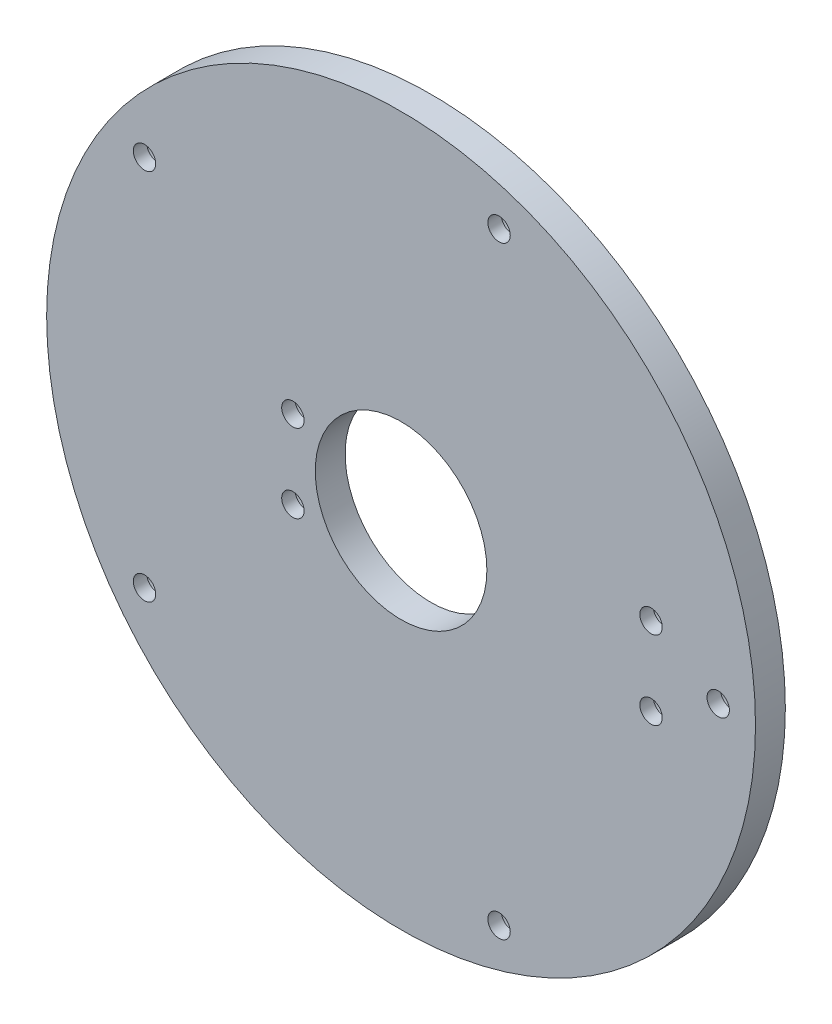
from build123d import *

# Parameters (mm, degrees)
SKETCH1_R           = 47.5
SKETCH1_R_2         = 2.75
SKETCH1_R_3         = 11.5
SKETCH1_R_4         = 1.5
BOSS_EXTRUDE2_DEPTH = 4
SKETCH1_5_R         = 2.75
SKETCH1_5_R_2       = 1.5
CUT_EXTRUDE1_DEPTH  = 2.2


with BuildPart() as part:
    # Sketch1 → Boss-Extrude2 (new body)
    with BuildSketch(Plane.XY):
        with Locations((47.5, 47.5)):
            Circle(SKETCH1_R)
        with Locations((81, 42.125)):
            Circle(SKETCH1_R_2, mode=Mode.SUBTRACT)
        with Locations((90, 47.5)):
            Circle(SKETCH1_R_2, mode=Mode.SUBTRACT)
        with Locations((81, 52.625)):
            Circle(SKETCH1_R_2, mode=Mode.SUBTRACT)
        with Locations((60.633222261, 87.919901943)):
            Circle(SKETCH1_R_2, mode=Mode.SUBTRACT)
        with Locations((13.116777739, 72.480873222)):
            Circle(SKETCH1_R_2, mode=Mode.SUBTRACT)
        with Locations((33, 52.625)):
            Circle(SKETCH1_R_2, mode=Mode.SUBTRACT)
        with Locations((33, 42.125)):
            Circle(SKETCH1_R_2, mode=Mode.SUBTRACT)
        with Locations((60.633222261, 7.080098057)):
            Circle(SKETCH1_R_2, mode=Mode.SUBTRACT)
        with Locations((13.116777739, 22.519126778)):
            Circle(SKETCH1_R_2, mode=Mode.SUBTRACT)
        with Locations((47.5, 47.5)):
            Circle(SKETCH1_R_3, mode=Mode.SUBTRACT)
        with Locations((13.116777739, 72.480873222)):
            Circle(SKETCH1_R_2)
        with Locations((13.116777739, 72.480873222)):
            Circle(SKETCH1_R_4, mode=Mode.SUBTRACT)
        with Locations((60.633222261, 87.919901943)):
            Circle(SKETCH1_R_2)
        with Locations((60.633222261, 87.919901943)):
            Circle(SKETCH1_R_4, mode=Mode.SUBTRACT)
        with Locations((33, 52.625)):
            Circle(SKETCH1_R_2)
        with Locations((33, 52.625)):
            Circle(SKETCH1_R_4, mode=Mode.SUBTRACT)
        with Locations((81, 52.625)):
            Circle(SKETCH1_R_2)
        with Locations((81, 52.625)):
            Circle(SKETCH1_R_4, mode=Mode.SUBTRACT)
        with Locations((90, 47.5)):
            Circle(SKETCH1_R_2)
        with Locations((90, 47.5)):
            Circle(SKETCH1_R_4, mode=Mode.SUBTRACT)
        with Locations((81, 42.125)):
            Circle(SKETCH1_R_2)
        with Locations((81, 42.125)):
            Circle(SKETCH1_R_4, mode=Mode.SUBTRACT)
        with Locations((33, 42.125)):
            Circle(SKETCH1_R_2)
        with Locations((33, 42.125)):
            Circle(SKETCH1_R_4, mode=Mode.SUBTRACT)
        with Locations((13.116777739, 22.519126778)):
            Circle(SKETCH1_R_2)
        with Locations((13.116777739, 22.519126778)):
            Circle(SKETCH1_R_4, mode=Mode.SUBTRACT)
        with Locations((60.633222261, 7.080098057)):
            Circle(SKETCH1_R_2)
        with Locations((60.633222261, 7.080098057)):
            Circle(SKETCH1_R_4, mode=Mode.SUBTRACT)
    extrude(amount=BOSS_EXTRUDE2_DEPTH)

    # Sketch1_5 → Cut-Extrude1 (cut)
    with BuildSketch(Plane.XY):
        with Locations((33, 52.625)):
            Circle(SKETCH1_5_R)
        with Locations((33, 52.625)):
            Circle(SKETCH1_5_R_2, mode=Mode.SUBTRACT)
        with Locations((33, 42.125)):
            Circle(SKETCH1_5_R)
        with Locations((33, 42.125)):
            Circle(SKETCH1_5_R_2, mode=Mode.SUBTRACT)
        with Locations((13.116777739, 22.519126778)):
            Circle(SKETCH1_5_R)
        with Locations((13.116777739, 22.519126778)):
            Circle(SKETCH1_5_R_2, mode=Mode.SUBTRACT)
        with Locations((13.116777739, 72.480873222)):
            Circle(SKETCH1_5_R)
        with Locations((13.116777739, 72.480873222)):
            Circle(SKETCH1_5_R_2, mode=Mode.SUBTRACT)
        with Locations((60.633222261, 87.919901943)):
            Circle(SKETCH1_5_R)
        with Locations((60.633222261, 87.919901943)):
            Circle(SKETCH1_5_R_2, mode=Mode.SUBTRACT)
        with Locations((81, 52.625)):
            Circle(SKETCH1_5_R)
        with Locations((81, 52.625)):
            Circle(SKETCH1_5_R_2, mode=Mode.SUBTRACT)
        with Locations((90, 47.5)):
            Circle(SKETCH1_5_R)
        with Locations((90, 47.5)):
            Circle(SKETCH1_5_R_2, mode=Mode.SUBTRACT)
        with Locations((81, 42.125)):
            Circle(SKETCH1_5_R)
        with Locations((81, 42.125)):
            Circle(SKETCH1_5_R_2, mode=Mode.SUBTRACT)
        with Locations((60.633222261, 7.080098057)):
            Circle(SKETCH1_5_R)
        with Locations((60.633222261, 7.080098057)):
            Circle(SKETCH1_5_R_2, mode=Mode.SUBTRACT)
    extrude(amount=CUT_EXTRUDE1_DEPTH, mode=Mode.SUBTRACT)


solid = part.part
